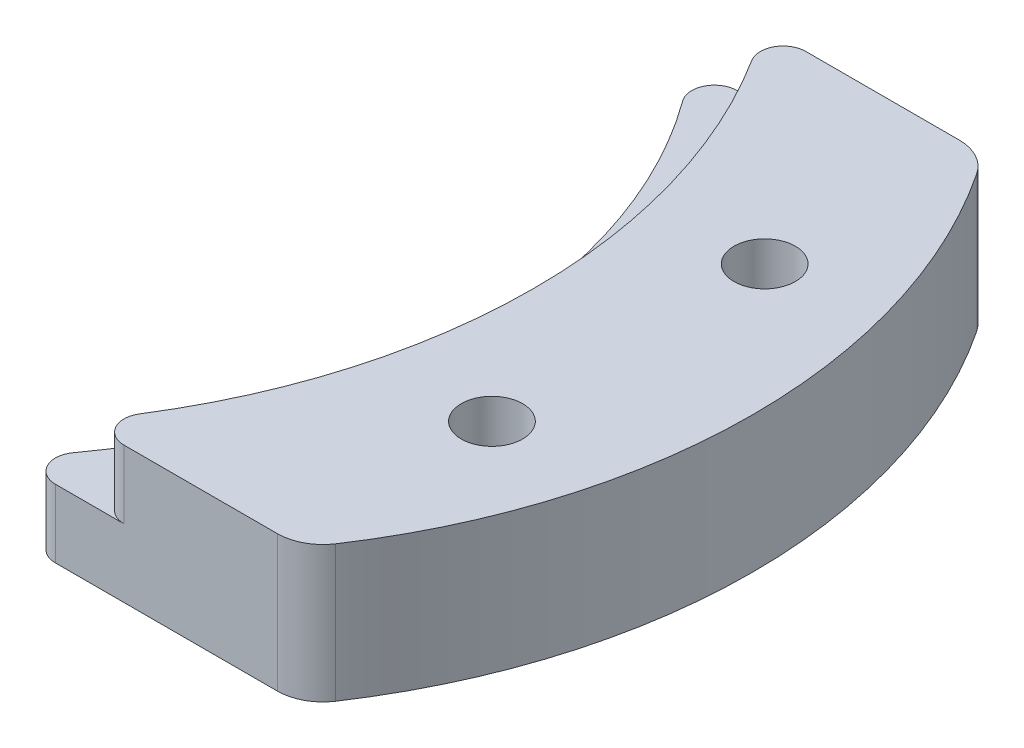
from build123d import *

# Parameters (mm, degrees)
EXTRUDE_1_DEPTH     = 6
SKETCH_2_R          = 25.25
SKETCH_2_R_2        = 22.75
CUT_EXTRUDE_1_DEPTH = 3
FILLET_1_R          = 1
FILLET_2_R          = 2
SKETCH_3_R          = 1.35
CUT_EXTRUDE_2_DEPTH = 7
CHAMFER_1_SIZE      = 1.5


with BuildPart() as part:
    # Эскиз1 → Бобышка-Вытянуть1 (new body)
    with BuildSketch(Plane(origin=(0, 0, 0), x_dir=(1, 0, 0), z_dir=(0, 1, 0))):
        with BuildLine():
            ThreePointArc((22.75, 0), (21.291887311, -8.013615586), (17.104458483, -15))
            Line((17.104458483, -15), (30, -15))
            ThreePointArc((30, -15), (34.878409373, 0), (30, 15))
            Line((30, 15), (17.104458483, 15))
            ThreePointArc((17.104458483, 15), (21.291887311, 8.013615586), (22.75, 0))
        make_face()
    extrude(amount=EXTRUDE_1_DEPTH)

    # Эскиз2 → Вырез-Вытянуть1 (cut)
    with BuildSketch(Plane(origin=(0, 6, 0), x_dir=(1, 0, 0), z_dir=(0, 1, 0))):
        Circle(SKETCH_2_R)
        Circle(SKETCH_2_R_2, mode=Mode.SUBTRACT)
    extrude(amount=-CUT_EXTRUDE_1_DEPTH, mode=Mode.SUBTRACT)

    # Скругление1
    fillet_1_edges = [part.edges().sort_by_distance(p)[0] for p in [
        (17.104458483, 1.5, -15),
        (17.104458483, 1.5, 15),
        (20.311634597, 4.5, 15),
        (20.311634597, 4.5, -15),
    ]]
    fillet(fillet_1_edges, radius=FILLET_1_R)

    # Скругление2
    fillet_2_edges = [part.edges().sort_by_distance(p)[0] for p in [
        (30, 3, -15),
        (30, 3, 15),
    ]]
    fillet(fillet_2_edges, radius=FILLET_2_R)

    # Эскиз3 → Вырез-Вытянуть2 (cut, through all)
    with BuildSketch(Plane(origin=(0, 6, 0), x_dir=(1, 0, 0), z_dir=(0, 1, 0))):
        with Locations((29.393876913, 6)):
            Circle(SKETCH_3_R)
        with Locations((29.393876913, -6)):
            Circle(SKETCH_3_R)
    extrude(amount=-CUT_EXTRUDE_2_DEPTH, mode=Mode.SUBTRACT)

    # Фаска1
    chamfer_1_edges = [part.edges().sort_by_distance(p)[0] for p in [
        (28.043876913, 0, -6),
        (28.043876913, 0, 6),
    ]]
    chamfer(chamfer_1_edges, length=CHAMFER_1_SIZE)


solid = part.part
